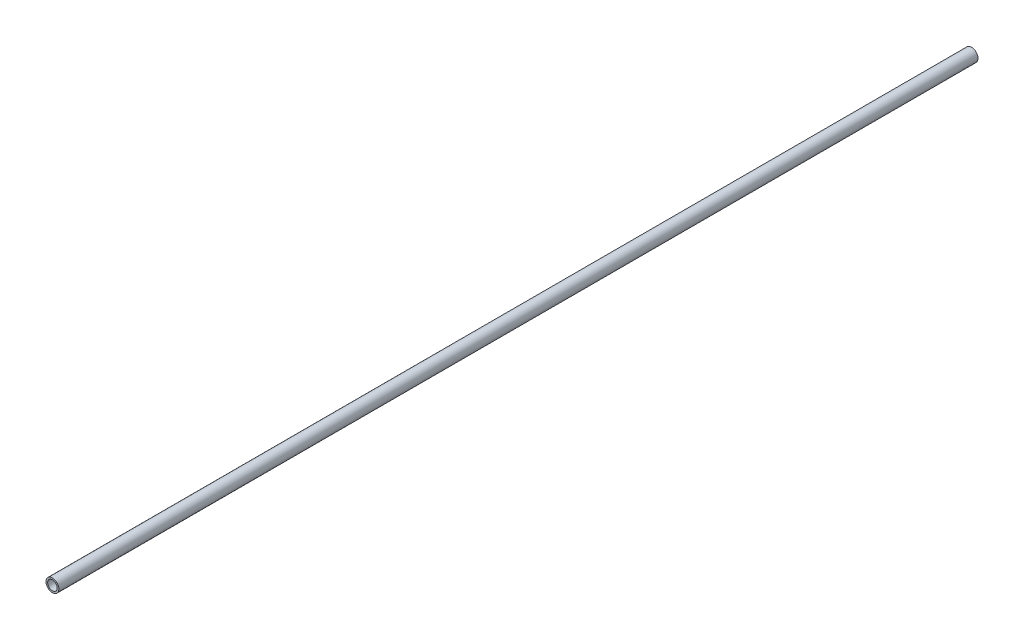
from build123d import *

# Parameters (mm, degrees)
SKETCH1_R           = 10.668
SKETCH1_R_2         = 7.8994
BOSS_EXTRUDE1_DEPTH = 1524


with BuildPart() as part:
    # Sketch1 → Boss-Extrude1 (new body)
    with BuildSketch(Plane.XY):
        Circle(SKETCH1_R)
        Circle(SKETCH1_R_2, mode=Mode.SUBTRACT)
    extrude(amount=BOSS_EXTRUDE1_DEPTH)


solid = part.part
